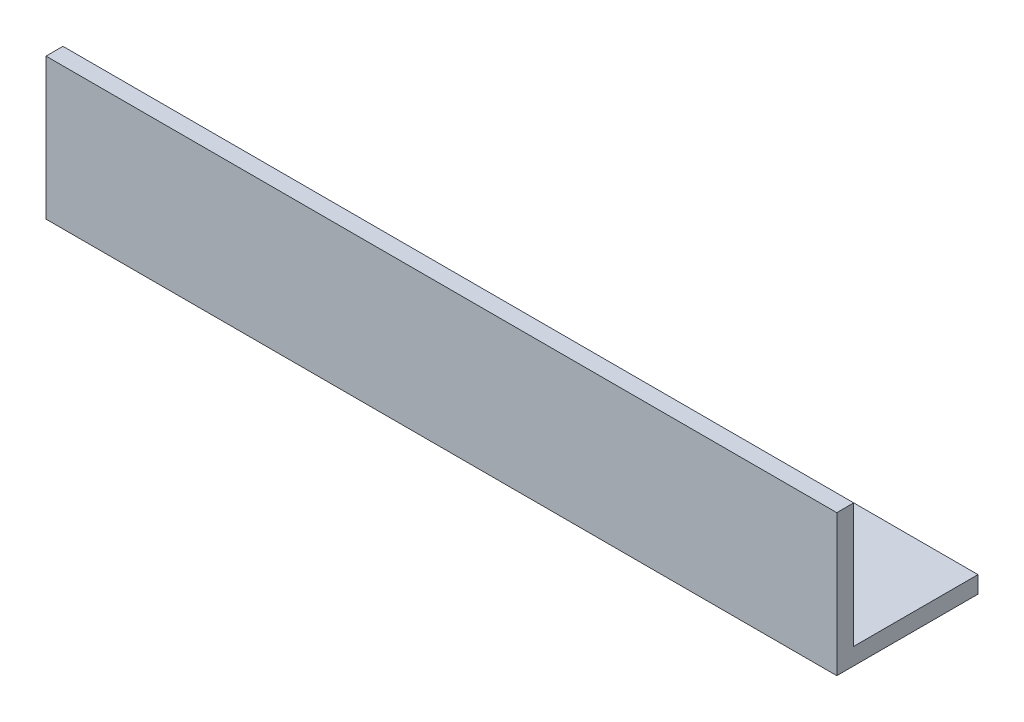
from build123d import *

# Parameters (mm, degrees)
EXTRUDE_1_DEPTH = 140


with BuildPart() as part:
    # Эскиз1 → Бобышка-Вытянуть1 (new body)
    with BuildSketch(Plane(origin=(0, 0, 0), x_dir=(0, 0, -1), z_dir=(1, 0, 0))):
        Polygon((0, 25), (0, 0), (25, 0), (25, 3), (3, 3), (3, 25), align=None)
    extrude(amount=EXTRUDE_1_DEPTH)


solid = part.part
